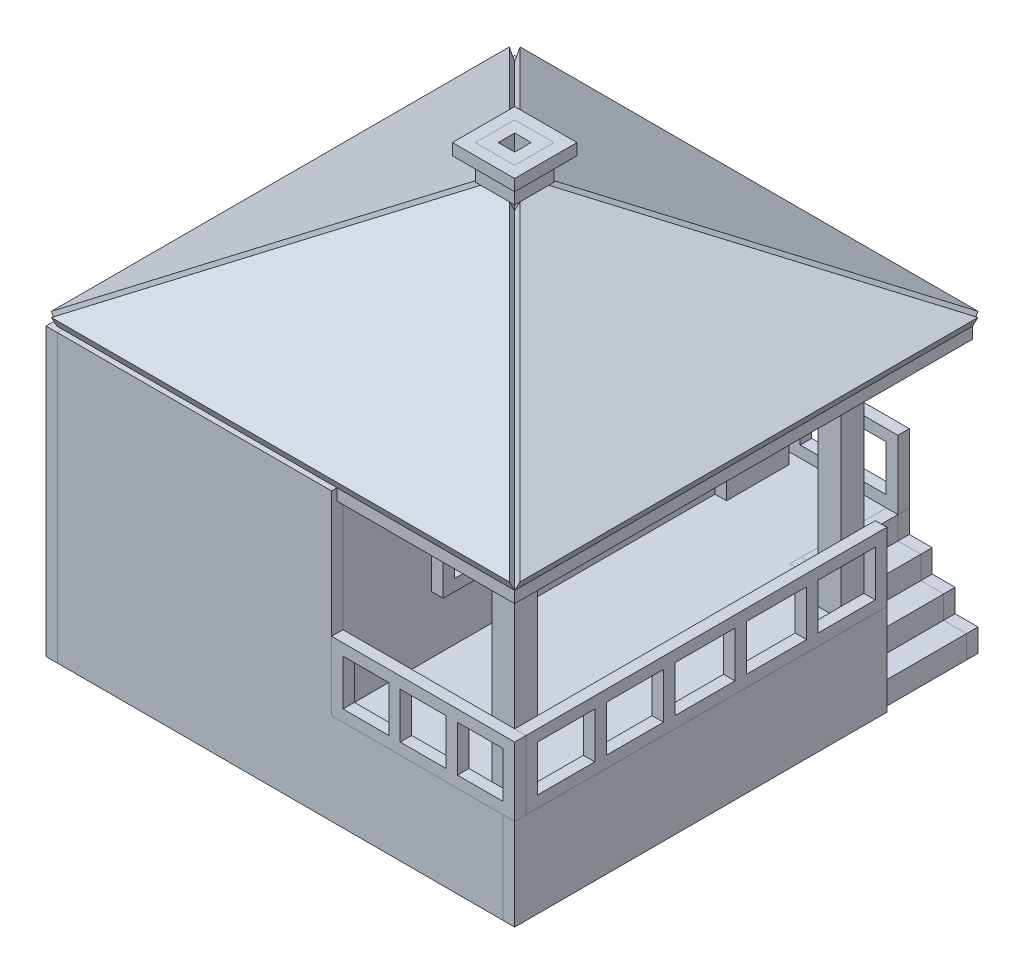
from build123d import *

# Parameters (mm, degrees)
EXTRUDE2_DEPTH    = 2
CIRPATTERN7_COUNT = 4
SKETCH4_W         = 81.882352942
SKETCH4_H         = 50
EXTRUDE3_DEPTH    = 2
EXTRUDE4_DEPTH    = 2
EXTRUDE5_DEPTH    = 2
SKETCH7_W         = 65
SKETCH7_H         = 16
EXTRUDE6_DEPTH    = 2
EXTRUDE7_DEPTH    = 2
SKETCH9_W         = 12.941176471
SKETCH9_H         = 16
EXTRUDE8_DEPTH    = 2
SKETCH11_W        = 14.882352942
SKETCH11_H        = 16
EXTRUDE9_DEPTH    = 2
EXTRUDE10_DEPTH   = 14.882353
SKETCH13_W        = 77.882352942
SKETCH13_H        = 36
EXTRUDE11_DEPTH   = 2
SKETCH16_W        = 31.058823529
SKETCH16_H        = 80
EXTRUDE13_DEPTH   = 2
SKETCH17_W        = 4
SKETCH17_H        = 4
EXTRUDE14_DEPTH   = 32
SKETCH18_W        = 4
SKETCH18_H        = 4
EXTRUDE16_DEPTH   = 32
SKETCH20_W        = 10.882352942
SKETCH20_H        = 25
EXTRUDE17_DEPTH   = 2
SKETCH21_W        = 30
SKETCH21_H        = 15
SKETCH21_W_2      = 12
SKETCH21_H_2      = 11
EXTRUDE18_DEPTH   = 2
SKETCH22_W        = 6.882352942
SKETCH22_H        = 6.882352942
SKETCH22_W_2      = 2.882352942
SKETCH22_H_2      = 2.882352942
EXTRUDE19_DEPTH   = 6
SKETCH23_W        = 10.882352942
SKETCH23_H        = 10.882352942
SKETCH23_W_2      = 6.882352942
SKETCH23_H_2      = 6.882352942
EXTRUDE20_DEPTH   = 2
SKETCH24_W        = 32
SKETCH24_H        = 12
SKETCH24_W_2      = 8
SKETCH24_H_2      = 8
EXTRUDE21_DEPTH   = 2
SKETCH25_W        = 63
SKETCH25_H        = 12
SKETCH25_W_2      = 10
SKETCH25_H_2      = 8
SKETCH25_W_3      = 10.5
EXTRUDE22_DEPTH   = 2
SKETCH26_W        = 30
SKETCH26_H        = 15
SKETCH26_W_2      = 12
SKETCH26_H_2      = 11
EXTRUDE23_DEPTH   = 2
SKETCH27_W        = 19.058823529
SKETCH27_H        = 12
SKETCH27_W_2      = 6.5
SKETCH27_H_2      = 8
EXTRUDE24_DEPTH   = 2


with BuildPart() as part:
    # Sketch3 → Extrude2 (new body)
    with BuildSketch(Plane(origin=(0, 16.60899654, 8.858131488), x_dir=(1, 0, 0), z_dir=(0, 0.882352941, 0.470588235))):
        Polygon((-40, -35.294117647), (-2.5, 7.205882353), (2.5, 7.205882353), (40, -35.294117647), align=None)
    extrude(amount=EXTRUDE2_DEPTH)


with BuildPart() as cirpattern7_1:
    # CirPattern7: pattern copy
    add(part.part.rotate(Axis((0, 0, 0), (0, 1, 0)), 1 * 360 / CIRPATTERN7_COUNT))


with BuildPart() as cirpattern7_2:
    # CirPattern7: pattern copy
    add(part.part.rotate(Axis((0, 0, 0), (0, 1, 0)), 2 * 360 / CIRPATTERN7_COUNT))


with BuildPart() as cirpattern7_3:
    # CirPattern7: pattern copy
    add(part.part.rotate(Axis((0, 0, 0), (0, 1, 0)), 3 * 360 / CIRPATTERN7_COUNT))


with BuildPart() as body_5:
    # Sketch4 → Extrude3 (new body)
    with BuildSketch(Plane(origin=(-40.941176471, 0, 0), x_dir=(0, 0, -1), z_dir=(1, 0, 0))):
        with Locations((0, -25)):
            Rectangle(SKETCH4_W, SKETCH4_H)
    extrude(amount=EXTRUDE3_DEPTH)


with BuildPart() as body_6:
    # Sketch5 → Extrude4 (new body)
    with BuildSketch(Plane.XY.offset(40.941176471)):
        Polygon((-38.941176471, 0), (8.941176471, 0), (8.941176471, -34), (38.941176471, -34), (38.941176471, -50), (-38.941176471, -50), align=None)
    extrude(amount=-EXTRUDE4_DEPTH)


with BuildPart() as body_7:
    # Sketch6 → Extrude5 (new body)
    with BuildSketch(Plane(origin=(0, 0, -40.941176471), x_dir=(-1, 0, 0), z_dir=(0, 0, -1))):
        Polygon((38.941176471, -50), (38.941176471, 0), (-8.941176471, 0), (-8.941176471, -34), (-28, -34), (-28, -38), (-32, -38), (-32, -42), (-36, -42), (-36, -46), (-40, -46), (-40, -50), align=None)
    extrude(amount=-EXTRUDE5_DEPTH)


with BuildPart() as body_8:
    # Sketch7 → Extrude6 (new body)
    with BuildSketch(Plane(origin=(38.941176471, 0, 0), x_dir=(0, 0, -1), z_dir=(1, 0, 0))):
        with Locations((-8.441176471, -42)):
            Rectangle(SKETCH7_W, SKETCH7_H)
    extrude(amount=EXTRUDE6_DEPTH)


with BuildPart() as body_9:
    # Sketch8 → Extrude7 (new body)
    with BuildSketch(Plane(origin=(0, -34, 0), x_dir=(1, 0, 0), z_dir=(0, 1, 0))):
        Polygon((38.941176471, -38.941176471), (8.941176471, -38.941176471), (8.941176471, 38.941176471), (26, 38.941176471), (26, 22.058823529), (38.941176471, 22.058823529), align=None)
    extrude(amount=-EXTRUDE7_DEPTH)


with BuildPart() as body_10:
    # Sketch9 → Extrude8 (new body)
    with BuildSketch(Plane(origin=(0, 0, -24.058823529), x_dir=(-1, 0, 0), z_dir=(0, 0, -1))):
        with Locations((-32.470588236, -42)):
            Rectangle(SKETCH9_W, SKETCH9_H)
    extrude(amount=-EXTRUDE8_DEPTH)


with BuildPart() as body_11:
    # Sketch11 → Extrude9 (new body)
    with BuildSketch(Plane(origin=(26, 0, 0), x_dir=(0, 0, -1), z_dir=(1, 0, 0))):
        with Locations((31.5, -42)):
            Rectangle(SKETCH11_W, SKETCH11_H)
    extrude(amount=EXTRUDE9_DEPTH)


with BuildPart() as body_12:
    # Sketch12 → Extrude10 (new body)
    with BuildSketch(Plane.XY.offset(-38.941176471)):
        Polygon((40, -46), (40, -50), (28, -50), (28, -38), (32, -38), (32, -42), (36, -42), (36, -46), align=None)
    extrude(amount=EXTRUDE10_DEPTH)


with BuildPart() as body_13:
    # Sketch13 → Extrude11 (new body)
    with BuildSketch(Plane(origin=(8.941176471, 0, 0), x_dir=(0, 0, -1), z_dir=(1, 0, 0))):
        with Locations((0, -18)):
            Rectangle(SKETCH13_W, SKETCH13_H)
    extrude(amount=-EXTRUDE11_DEPTH)


with BuildPart() as body_14:
    # Sketch16 → Extrude13 (new body)
    with BuildSketch(Plane(origin=(0, 0, 0), x_dir=(-1, 0, 0), z_dir=(0, 1, 0))):
        with Locations((-24.470588235, 0)):
            Rectangle(SKETCH16_W, SKETCH16_H)
    extrude(amount=-EXTRUDE13_DEPTH)


with BuildPart() as body_15:
    # Sketch17 → Extrude14 (new body)
    with BuildSketch(Plane(origin=(0, -34, 0), x_dir=(1, 0, 0), z_dir=(0, 1, 0))):
        with Locations((36.941176471, -36.941176471)):
            Rectangle(SKETCH17_W, SKETCH17_H)
    extrude(amount=EXTRUDE14_DEPTH)


with BuildPart() as body_16:
    # Sketch18 → Extrude16 (new body)
    with BuildSketch(Plane(origin=(0, -34, 0), x_dir=(1, 0, 0), z_dir=(0, 1, 0))):
        with Locations((36.941176471, 20.058823529)):
            Rectangle(SKETCH18_W, SKETCH18_H)
    extrude(amount=EXTRUDE16_DEPTH)


with BuildPart() as body_17:
    # Sketch20 → Extrude17 (new body)
    with BuildSketch(Plane(origin=(8.941176471, 0, 0), x_dir=(0, 0, -1), z_dir=(1, 0, 0))):
        with Locations((31.5, -21.5)):
            Rectangle(SKETCH20_W, SKETCH20_H)
    extrude(amount=EXTRUDE17_DEPTH)


with BuildPart() as body_18:
    # Sketch21 → Extrude18 (new body)
    with BuildSketch(Plane(origin=(8.941176471, 0, 0), x_dir=(0, 0, -1), z_dir=(1, 0, 0))):
        with Locations((-8.441176471, -16.5)):
            Rectangle(SKETCH21_W, SKETCH21_H)
        with Locations((-1.441176471, -16.5)):
            Rectangle(SKETCH21_W_2, SKETCH21_H_2, mode=Mode.SUBTRACT)
        with Locations((-15.441176471, -16.5)):
            Rectangle(SKETCH21_W_2, SKETCH21_H_2, mode=Mode.SUBTRACT)
    extrude(amount=EXTRUDE18_DEPTH)


with BuildPart() as body_19:
    # Sketch22 → Extrude19 (new body)
    with BuildSketch(Plane.XZ.offset(-21.764705882)):
        Rectangle(SKETCH22_W, SKETCH22_H)
        Rectangle(SKETCH22_W_2, SKETCH22_H_2, mode=Mode.SUBTRACT)
    extrude(amount=-EXTRUDE19_DEPTH)


with BuildPart() as body_20:
    # Sketch23 → Extrude20 (new body)
    with BuildSketch(Plane(origin=(0, 27.764705882, 0), x_dir=(1, 0, 0), z_dir=(0, 1, 0))):
        Rectangle(SKETCH23_W, SKETCH23_H)
        Rectangle(SKETCH23_W_2, SKETCH23_H_2, mode=Mode.SUBTRACT)
    extrude(amount=-EXTRUDE20_DEPTH)


with BuildPart() as body_21:
    # Sketch24 → Extrude21 (new body)
    with BuildSketch(Plane.XY.offset(38.941176471)):
        with Locations((24.941176471, -28)):
            Rectangle(SKETCH24_W, SKETCH24_H)
        with Locations((34.941176471, -28)):
            Rectangle(SKETCH24_W_2, SKETCH24_H_2, mode=Mode.SUBTRACT)
        with Locations((14.941176471, -28)):
            Rectangle(SKETCH24_W_2, SKETCH24_H_2, mode=Mode.SUBTRACT)
        with Locations((24.941176471, -28)):
            Rectangle(SKETCH24_W_2, SKETCH24_H_2, mode=Mode.SUBTRACT)
    extrude(amount=EXTRUDE21_DEPTH)


with BuildPart() as body_22:
    # Sketch25 → Extrude22 (new body)
    with BuildSketch(Plane(origin=(38.941176471, 0, 0), x_dir=(0, 0, -1), z_dir=(1, 0, 0))):
        with Locations((-7.441176471, -28)):
            Rectangle(SKETCH25_W, SKETCH25_H)
        with Locations((17.058823529, -28)):
            Rectangle(SKETCH25_W_2, SKETCH25_H_2, mode=Mode.SUBTRACT)
        with Locations((-31.941176471, -28)):
            Rectangle(SKETCH25_W_2, SKETCH25_H_2, mode=Mode.SUBTRACT)
        with Locations((-7.691176471, -28)):
            Rectangle(SKETCH25_W_3, SKETCH25_H_2, mode=Mode.SUBTRACT)
        with Locations((4.808823529, -28)):
            Rectangle(SKETCH25_W_3, SKETCH25_H_2, mode=Mode.SUBTRACT)
        with Locations((-19.941176471, -28)):
            Rectangle(SKETCH25_W_2, SKETCH25_H_2, mode=Mode.SUBTRACT)
    extrude(amount=EXTRUDE22_DEPTH)


with BuildPart() as body_23:
    # Sketch26 → Extrude23 (new body)
    with BuildSketch(Plane(origin=(0, 0, -40.941176471), x_dir=(-1, 0, 0), z_dir=(0, 0, -1))):
        with Locations((16.058823529, -16.5)):
            Rectangle(SKETCH26_W, SKETCH26_H)
        with Locations((23.058823529, -16.5)):
            Rectangle(SKETCH26_W_2, SKETCH26_H_2, mode=Mode.SUBTRACT)
        with Locations((9.058823529, -16.5)):
            Rectangle(SKETCH26_W_2, SKETCH26_H_2, mode=Mode.SUBTRACT)
    extrude(amount=EXTRUDE23_DEPTH)


with BuildPart() as body_24:
    # Sketch27 → Extrude24 (new body)
    with BuildSketch(Plane(origin=(0, 0, -40.941176471), x_dir=(-1, 0, 0), z_dir=(0, 0, -1))):
        with Locations((-18.470588235, -28)):
            Rectangle(SKETCH27_W, SKETCH27_H)
        with Locations((-14.191176471, -28)):
            Rectangle(SKETCH27_W_2, SKETCH27_H_2, mode=Mode.SUBTRACT)
        with Locations((-22.691176471, -28)):
            Rectangle(SKETCH27_W_2, SKETCH27_H_2, mode=Mode.SUBTRACT)
    extrude(amount=-EXTRUDE24_DEPTH)


solid = Compound([part.part, cirpattern7_1.part, cirpattern7_2.part, cirpattern7_3.part, body_5.part, body_6.part, body_7.part, body_8.part, body_9.part, body_10.part, body_11.part, body_12.part, body_13.part, body_14.part, body_15.part, body_16.part, body_17.part, body_18.part, body_19.part, body_20.part, body_21.part, body_22.part, body_23.part, body_24.part])
